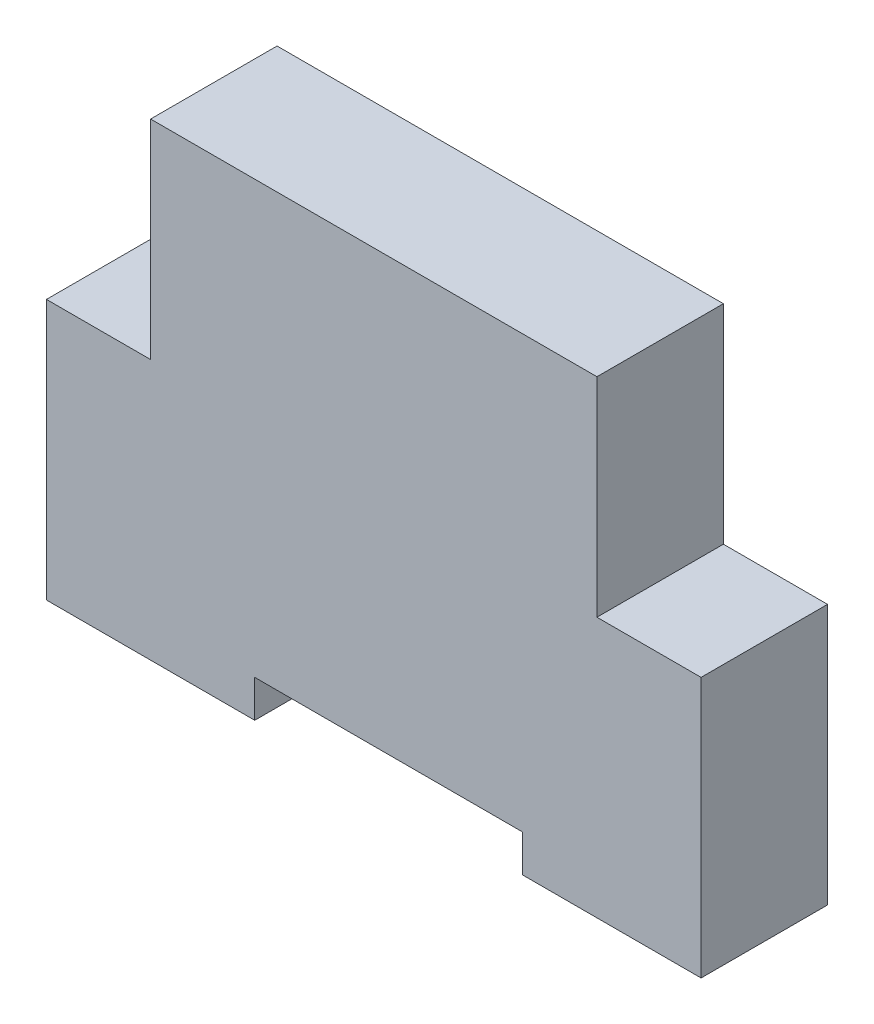
from build123d import *

# Parameters (mm, degrees)
BOSS_EXTRUDE1_DEPTH = 17


with BuildPart() as part:
    # Sketch1 → Boss-Extrude1 (new body)
    with BuildSketch(Plane.XY):
        Polygon((-32, 58), (28, 58), (28, 30), (42, 30), (42, -5), (18, -5), (18, 0), (-18, 0), (-18, -5), (-46, -5), (-46, 30), (-32, 30), align=None)
    extrude(amount=BOSS_EXTRUDE1_DEPTH)


solid = part.part
